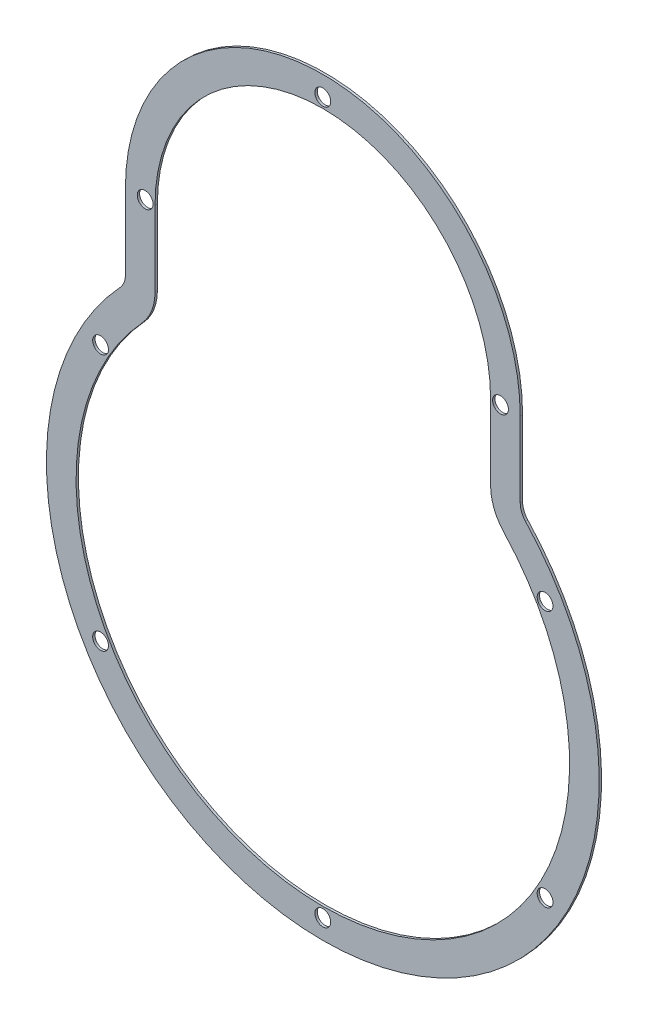
from build123d import *

# Parameters (mm, degrees)
SKETCH1_R           = 2.54
BOSS_EXTRUDE2_DEPTH = 0.762


with BuildPart() as part:
    # Sketch1 → Boss-Extrude2 (new body)
    with BuildSketch(Plane.XY):
        with BuildLine():
            Line((-63.5, 88.9), (-63.5, 64.757547823))
            ThreePointArc((-63.5, 64.757547823), (-63.938471715, 62.438855663), (-65.193333333, 60.440377968))
            ThreePointArc((-65.193333333, 60.440377968), (0, -88.9), (65.193333333, 60.440377968))
            ThreePointArc((65.193333333, 60.440377968), (63.938471715, 62.438855663), (63.5, 64.757547823))
            Line((63.5, 64.757547823), (63.5, 88.9))
            ThreePointArc((63.5, 88.9), (0, 152.4), (-63.5, 88.9))
        make_face()
        with Locations((-71.490397082, -41.275)):
            Circle(SKETCH1_R, mode=Mode.SUBTRACT)
        with Locations((-71.490397082, 41.275)):
            Circle(SKETCH1_R, mode=Mode.SUBTRACT)
        with Locations((-57.15, 88.9)):
            Circle(SKETCH1_R, mode=Mode.SUBTRACT)
        with Locations((0, 146.05)):
            Circle(SKETCH1_R, mode=Mode.SUBTRACT)
        with Locations((57.15, 88.9)):
            Circle(SKETCH1_R, mode=Mode.SUBTRACT)
        with Locations((71.490397082, 41.275)):
            Circle(SKETCH1_R, mode=Mode.SUBTRACT)
        with Locations((71.490397082, -41.275)):
            Circle(SKETCH1_R, mode=Mode.SUBTRACT)
        with Locations((0, -82.55)):
            Circle(SKETCH1_R, mode=Mode.SUBTRACT)
        with BuildLine():
            Line((-53.975, 88.9), (-53.975, 64.757547823))
            ThreePointArc((-53.975, 64.757547823), (-55.071179287, 58.960817422), (-58.208333333, 53.964623186))
            ThreePointArc((-58.208333333, 53.964623186), (0, -79.375), (58.208333333, 53.964623186))
            ThreePointArc((58.208333333, 53.964623186), (55.071179287, 58.960817422), (53.975, 64.757547823))
            Line((53.975, 64.757547823), (53.975, 88.9))
            ThreePointArc((53.975, 88.9), (0, 142.875), (-53.975, 88.9))
        make_face(mode=Mode.SUBTRACT)
    extrude(amount=BOSS_EXTRUDE2_DEPTH)


solid = part.part
